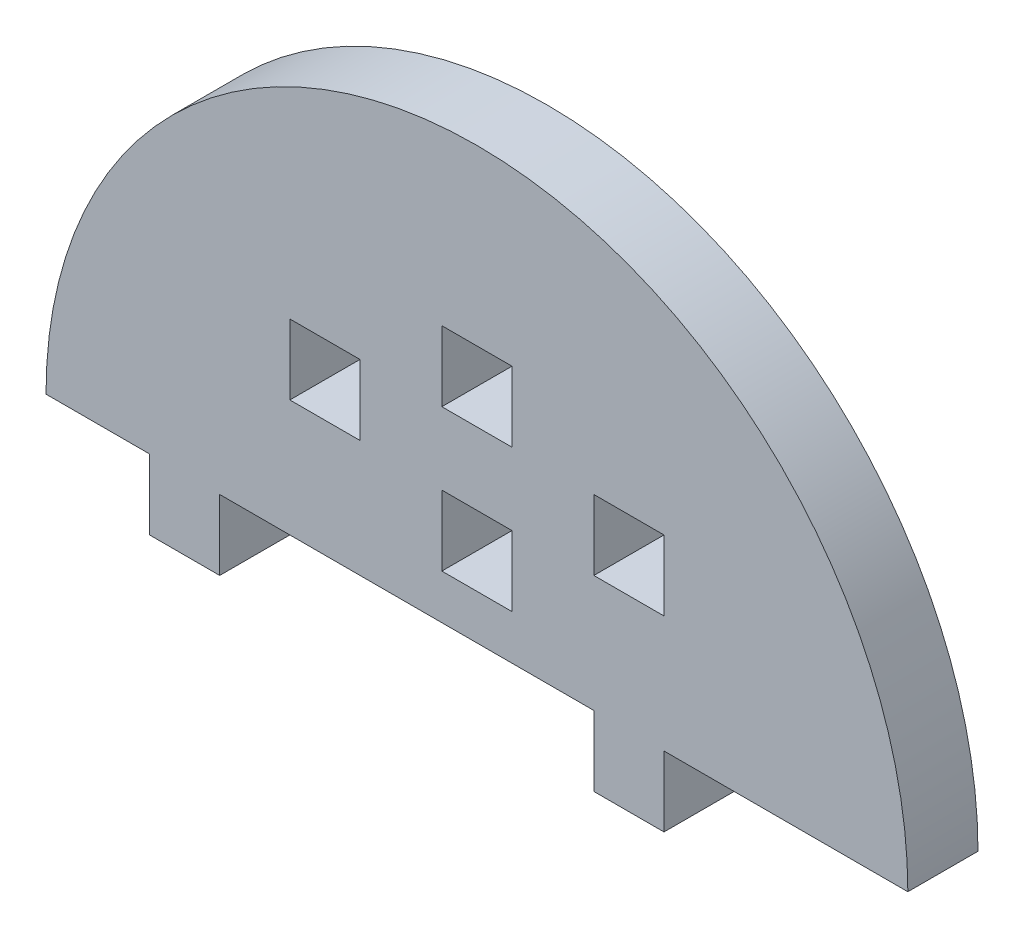
from build123d import *

# Parameters (mm, degrees)
MODEL_W             = 6
MODEL_H             = 6
BOSS_EXTRUDE1_DEPTH = 6


with BuildPart() as part:
    # Model → Boss-Extrude1 (new body)
    with BuildSketch(Plane.XY):
        with BuildLine():
            Line((3428.744099931, 1203.660512719), (3428.744099931, 1197.660512719))
            Line((3428.744099931, 1197.660512719), (3434.744099931, 1197.660512719))
            Line((3434.744099931, 1197.660512719), (3434.744099931, 1203.660512719))
            Line((3434.744099931, 1203.660512719), (3455.601242788, 1203.660512719))
            ThreePointArc((3455.601242788, 1203.660512719), (3418.744099931, 1240.517655576), (3381.886957074, 1203.660512719))
            Line((3381.886957074, 1203.660512719), (3390.744099931, 1203.660512719))
            Line((3390.744099931, 1203.660512719), (3390.744099931, 1197.660512719))
            Line((3390.744099931, 1197.660512719), (3396.744099931, 1197.660512719))
            Line((3396.744099931, 1197.660512719), (3396.744099931, 1203.660512719))
            Line((3396.744099931, 1203.660512719), (3428.744099931, 1203.660512719))
        make_face()
        with Locations((3431.744099931, 1216.660512719)):
            Rectangle(MODEL_W, MODEL_H, mode=Mode.SUBTRACT)
        with Locations((3405.744099931, 1216.660512719)):
            Rectangle(MODEL_W, MODEL_H, mode=Mode.SUBTRACT)
        with Locations((3418.744099931, 1222.660512719)):
            Rectangle(MODEL_W, MODEL_H, mode=Mode.SUBTRACT)
        with Locations((3418.744099931, 1210.484971552)):
            Rectangle(MODEL_W, MODEL_H, mode=Mode.SUBTRACT)
    extrude(amount=BOSS_EXTRUDE1_DEPTH)


solid = part.part
